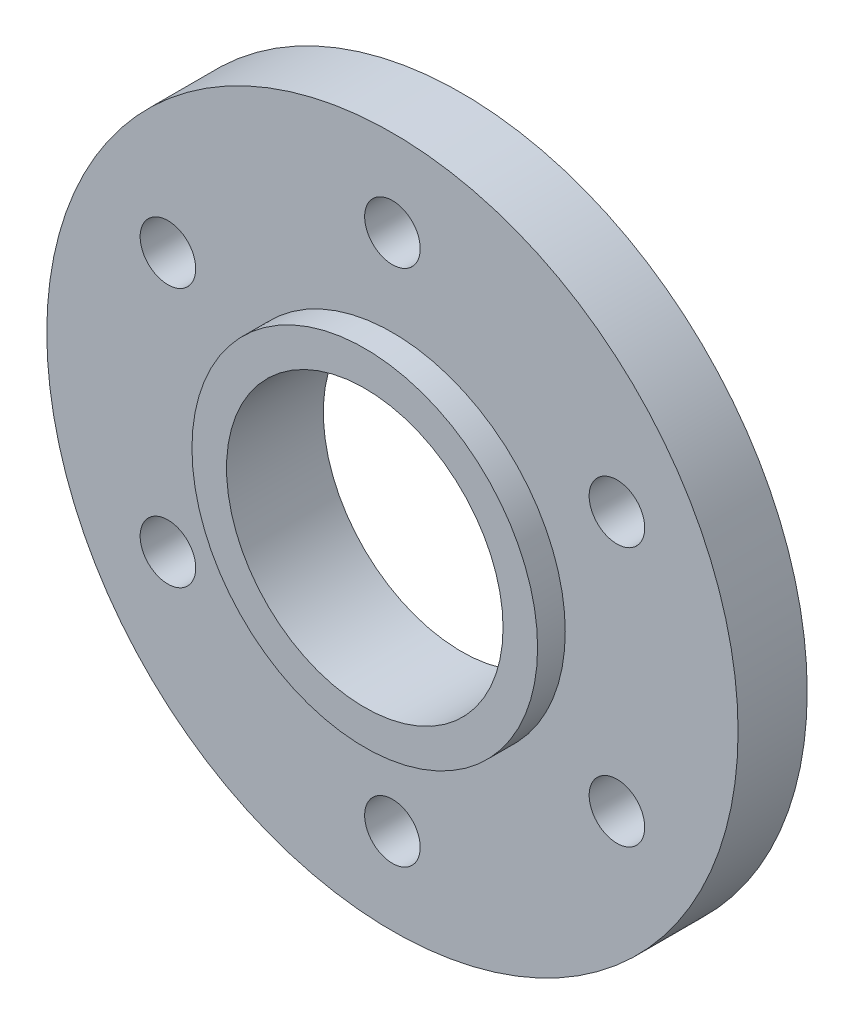
from build123d import *

# Parameters (mm, degrees)
SKETCH1_R           = 31.75
BOSS_EXTRUDE1_DEPTH = 6.35
SKETCH2_R           = 12.7
SKETCH2_R_2         = 2.5527
CUT_EXTRUDE1_DEPTH  = 7.35
SKETCH3_R           = 15.875
SKETCH3_R_2         = 12.7
BOSS_EXTRUDE2_DEPTH = 2.54


with BuildPart() as part:
    # Sketch1 → Boss-Extrude1 (new body)
    with BuildSketch(Plane.XY):
        Circle(SKETCH1_R)
    extrude(amount=BOSS_EXTRUDE1_DEPTH)

    # Sketch2 → Cut-Extrude1 (cut, through all)
    with BuildSketch(Plane.XY.offset(6.35)):
        Circle(SKETCH2_R)
        with Locations((0, 23.8125)):
            Circle(SKETCH2_R_2)
        with Locations((20.622229928, 11.90625)):
            Circle(SKETCH2_R_2)
        with Locations((20.622229928, -11.90625)):
            Circle(SKETCH2_R_2)
        with Locations((0, -23.8125)):
            Circle(SKETCH2_R_2)
        with Locations((-20.622229928, -11.90625)):
            Circle(SKETCH2_R_2)
        with Locations((-20.622229928, 11.90625)):
            Circle(SKETCH2_R_2)
    extrude(amount=-CUT_EXTRUDE1_DEPTH, mode=Mode.SUBTRACT)

    # Sketch3 → Boss-Extrude2 (add)
    with BuildSketch(Plane.XY.offset(6.35)):
        Circle(SKETCH3_R)
        Circle(SKETCH3_R_2, mode=Mode.SUBTRACT)
    extrude(amount=BOSS_EXTRUDE2_DEPTH)


solid = part.part
